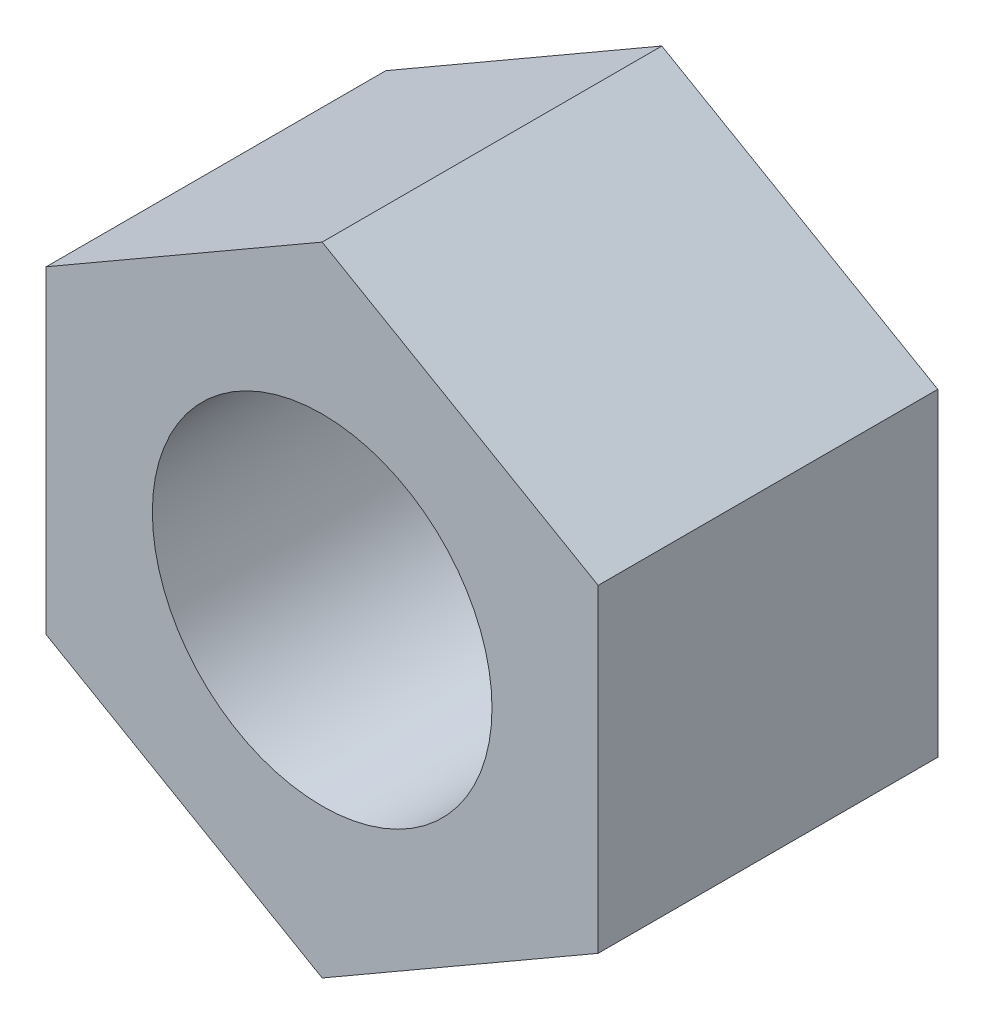
from build123d import *

# Parameters (mm, degrees)
SKETCH1_R          = 4
BASE_EXTRUDE_DEPTH = 8


with BuildPart() as part:
    # Sketch1 → Base-Extrude (new body)
    with BuildSketch(Plane.XY):
        Polygon((0, 7.505553499), (-6.5, 3.75277675), (-6.5, -3.75277675), (0, -7.505553499), (6.5, -3.75277675), (6.5, 3.75277675), align=None)
        Circle(SKETCH1_R, mode=Mode.SUBTRACT)
    extrude(amount=BASE_EXTRUDE_DEPTH)


solid = part.part
